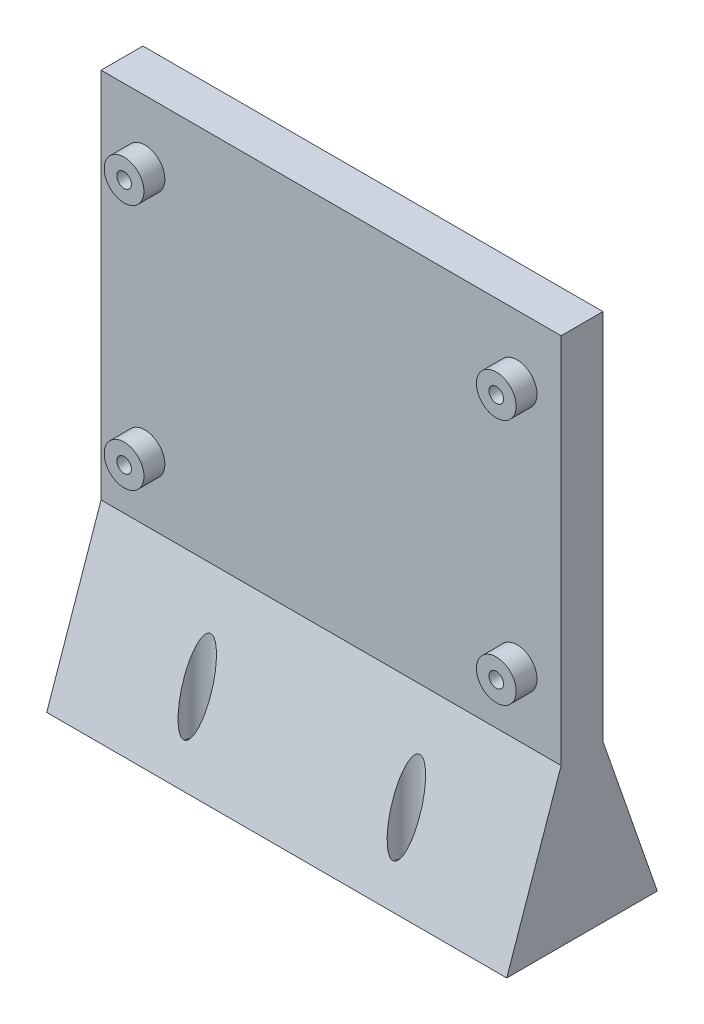
from build123d import *

# Parameters (mm, degrees)
SKETCH1_W                      = 110
SKETCH1_H                      = 89
SKETCH1_R                      = 4.75
BOSS_EXTRUDE1_DEPTH            = 10
SKETCH1_3_R                    = 4.75
SKETCH1_3_R_2                  = 1.75
BOSS_EXTRUDE2_DEPTH            = 15
SKETCH2_W                      = 110
SKETCH2_H                      = 36
CBORE_FOR_M3_SHCS1_D           = 3.4
CBORE_FOR_M3_SHCS1_CBORE_D     = 6.5
CBORE_FOR_M3_SHCS1_CBORE_DEPTH = 33


with BuildPart() as part:
    # Sketch1 → Boss-Extrude1 (new body)
    with BuildSketch(Plane.XY):
        Rectangle(SKETCH1_W, SKETCH1_H)
        with Locations((44.5, 29.5)):
            Circle(SKETCH1_R, mode=Mode.SUBTRACT)
        with Locations((44.5, -29.5)):
            Circle(SKETCH1_R, mode=Mode.SUBTRACT)
        with Locations((-44.5, -29.5)):
            Circle(SKETCH1_R, mode=Mode.SUBTRACT)
        with Locations((-44.5, 29.5)):
            Circle(SKETCH1_R, mode=Mode.SUBTRACT)
    extrude(amount=BOSS_EXTRUDE1_DEPTH)

    # Sketch1_3 → Boss-Extrude2 (add)
    with BuildSketch(Plane.XY):
        with Locations((-44.5, 29.5)):
            Circle(SKETCH1_3_R)
        with Locations((-44.5, 29.5)):
            Circle(SKETCH1_3_R_2, mode=Mode.SUBTRACT)
        with Locations((44.5, 29.5)):
            Circle(SKETCH1_3_R)
        with Locations((44.5, 29.5)):
            Circle(SKETCH1_3_R_2, mode=Mode.SUBTRACT)
        with Locations((44.5, -29.5)):
            Circle(SKETCH1_3_R)
        with Locations((44.5, -29.5)):
            Circle(SKETCH1_3_R_2, mode=Mode.SUBTRACT)
        with Locations((-44.5, -29.5)):
            Circle(SKETCH1_3_R)
        with Locations((-44.5, -29.5)):
            Circle(SKETCH1_3_R_2, mode=Mode.SUBTRACT)
    extrude(amount=BOSS_EXTRUDE2_DEPTH)

    # Sketch2 → section 1 of loft1
    with BuildSketch(Plane(origin=(0, -82, 0), x_dir=(1, 0, 0), z_dir=(0, 1, 0)), mode=Mode.PRIVATE) as loft1_s1:
        with Locations((0, -5)):
            Rectangle(SKETCH2_W, SKETCH2_H)
    # loft from a face of the part (loft1)
    loft([part.faces().sort_by_distance((0, -44.5, 5))[0], loft1_s1.sketch])

    # CBORE for M3 SHCS1 (through all)
    with Locations(Plane(origin=(0, -44.5, 0), x_dir=(1, 0, 0), z_dir=(0, 1, 0))):
        with Locations((-25, 7), (25, 7), (25, -17), (-25, -17)):
            CounterBoreHole(CBORE_FOR_M3_SHCS1_D / 2, CBORE_FOR_M3_SHCS1_CBORE_D / 2, CBORE_FOR_M3_SHCS1_CBORE_DEPTH)


solid = part.part
